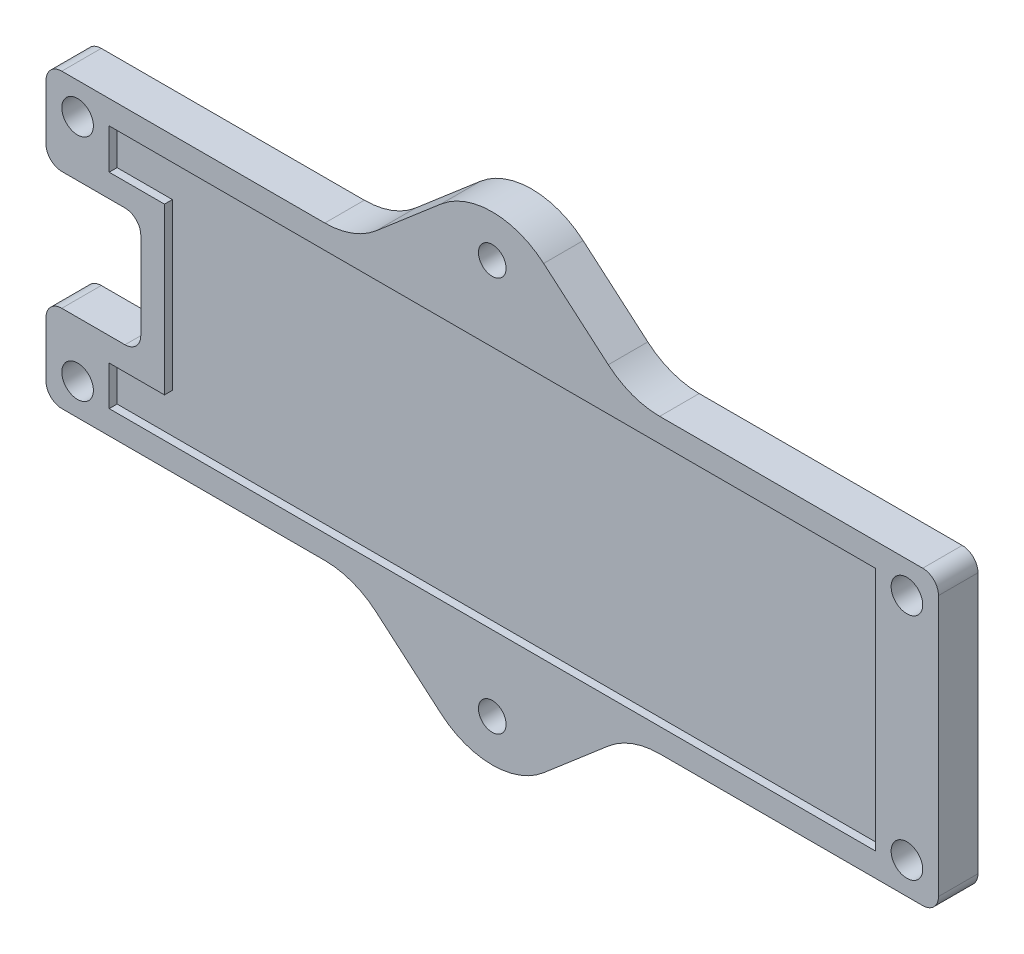
from build123d import *

# Parameters (mm, degrees)
SKETCH_1_W          = 113
SKETCH_1_H          = 37
SKETCH_1_R          = 2
EXTRUDE_1_DEPTH     = 2.5
SKETCH_2_W          = 12
SKETCH_2_H          = 15
CUT_EXTRUDE_1_DEPTH = 6
CUT_EXTRUDE_2_DEPTH = 1
FILLET_1_R          = 2
FILLET_2_R          = 2
EXTRUDE_2_DEPTH     = 5
FILLET_3_R          = 10
SKETCH_5_R          = 1.75
CUT_EXTRUDE_3_DEPTH = 6


with BuildPart() as part:
    # 草图1 → 凸台-拉伸1 (new body, symmetric)
    with BuildSketch(Plane.XY):
        Rectangle(SKETCH_1_W, SKETCH_1_H)
        with Locations((52.5, 14.5)):
            Circle(SKETCH_1_R, mode=Mode.SUBTRACT)
        with Locations((52.5, -14.5)):
            Circle(SKETCH_1_R, mode=Mode.SUBTRACT)
        with Locations((-52.5, -14.5)):
            Circle(SKETCH_1_R, mode=Mode.SUBTRACT)
        with Locations((-52.5, 14.5)):
            Circle(SKETCH_1_R, mode=Mode.SUBTRACT)
    extrude(amount=EXTRUDE_1_DEPTH, both=True)

    # 草图2 → 切除-拉伸1 (cut, through all)
    with BuildSketch(Plane(origin=(0, 0, -2.5), x_dir=(-1, 0, 0), z_dir=(0, 0, -1))):
        with Locations((50.5, 0)):
            Rectangle(SKETCH_2_W, SKETCH_2_H)
    extrude(amount=-CUT_EXTRUDE_1_DEPTH, mode=Mode.SUBTRACT)

    # 草图3 → 切除-拉伸2 (cut)
    with BuildSketch(Plane(origin=(0, 0, -2.5), x_dir=(-1, 0, 0), z_dir=(0, 0, -1))):
        Polygon((-48.5, -15.5), (48.500097741, -15.5), (48.500097741, -10.5), (41.5, -10.5), (41.5, 10.420732232), (48.500097741, 10.420732232), (48.526939222, 15.5), (-48.5, 15.5), align=None)
    cut_extrude_2 = extrude(amount=-CUT_EXTRUDE_2_DEPTH, mode=Mode.SUBTRACT)

    # 圆角1
    fillet_1_edges = [part.edges().sort_by_distance(p)[0] for p in [
        (48.5, -15.5, -2),
        (48.5, 15.5, -2),
        (-48.526939222, 15.5, -2),
        (-48.500097741, 10.420732232, -2),
        (-41.5, 10.420732232, -2),
        (-41.5, -10.5, -2),
        (-48.500097741, -10.5, -2),
        (-48.500097741, -15.5, -2),
    ]]
    fillet(fillet_1_edges, radius=FILLET_1_R)

    # 圆角2
    fillet_2_edges = [part.edges().sort_by_distance(p)[0] for p in [
        (-56.5, 7.5, 0),
        (-56.5, -7.5, 0),
        (-44.5, -7.5, 0),
        (-44.5, 7.5, 0),
        (-56.5, 18.5, 0),
        (56.5, 18.5, 0),
        (56.5, -18.5, 0),
        (-56.5, -18.5, 0),
    ]]
    fillet(fillet_2_edges, radius=FILLET_2_R)

    # 草图4 → 凸台-拉伸2 (add)
    with BuildSketch(Plane(origin=(0, 0, -2.5), x_dir=(-1, 0, 0), z_dir=(0, 0, -1))):
        Polygon((17.5, 18.5), (0, 33.5), (-17.5, 18.5), align=None)
        Polygon((17.5, -18.5), (-17.5, -18.5), (0, -33.5), align=None)
    extrude(amount=-EXTRUDE_2_DEPTH)

    # 圆角3
    fillet_3_edges = [part.edges().sort_by_distance(p)[0] for p in [
        (-17.5, 18.5, 0),
        (17.5, 18.5, 0),
        (0, 33.5, 0),
        (0, -33.5, 0),
        (17.5, -18.5, 0),
        (-17.5, -18.5, 0),
    ]]
    fillet(fillet_3_edges, radius=FILLET_3_R)

    # 草图5 → 切除-拉伸3 (cut, through all)
    with BuildSketch(Plane(origin=(0, 0, -2.5), x_dir=(-1, 0, 0), z_dir=(0, 0, -1))):
        with Locations((0, -25)):
            Circle(SKETCH_5_R)
        with Locations((0, 25)):
            Circle(SKETCH_5_R)
    extrude(amount=-CUT_EXTRUDE_3_DEPTH, mode=Mode.SUBTRACT)

    # 镜向1: 切除-拉伸2 across plane
    add(cut_extrude_2.mirror(Plane.XY), mode=Mode.SUBTRACT)


solid = part.part
